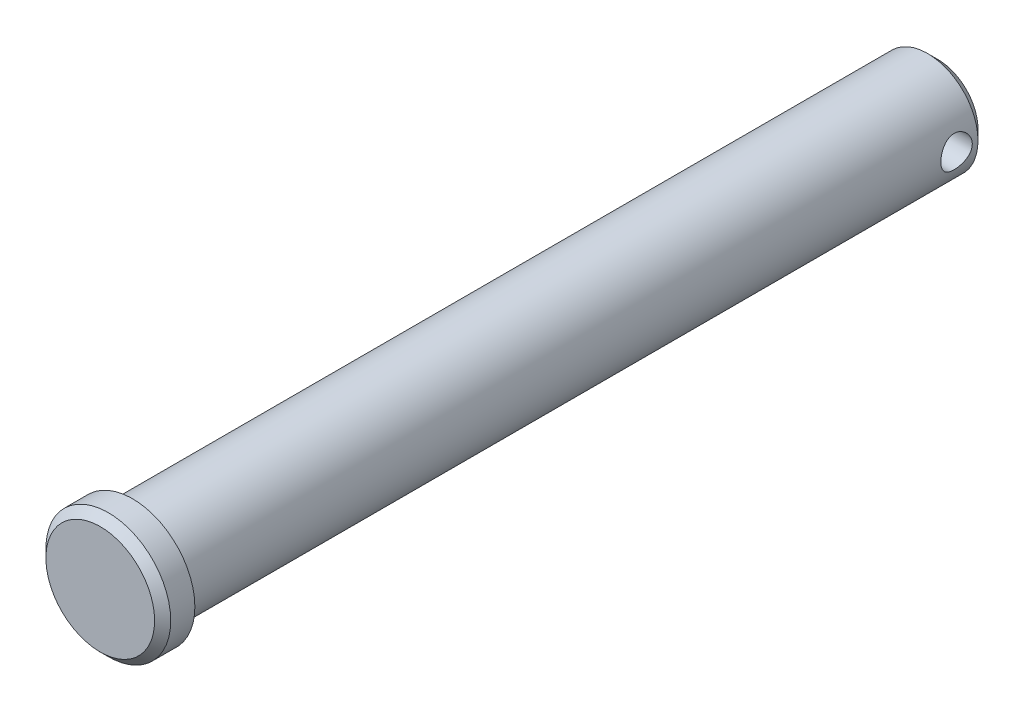
from build123d import *

# Parameters (mm, degrees)
CUT_EXTRUDE1_DEPTH      = 54.992777072
CUT_EXTRUDE1_DEPTH_BACK = 54.992777072
SKETCH3_R               = 1.9812


with BuildPart() as part:
    # Sketch2 → Revolve1 (revolve)
    with BuildSketch(Plane(origin=(0, 0, 0), x_dir=(0, 0, -1), z_dir=(1, 0, 0))):
        Polygon((51.562, 6.35), (-48.768, 6.35), (-48.768, 7.874), (-51.816, 7.874), (-52.832, 6.858), (-52.832, 0), (52.832, 0), (52.832, 5.08), align=None)
    revolve(axis=Axis((0, 0, 52.832), (0, 0, -1)))

    # Sketch3 → Cut-Extrude1 (cut, two sides: drawn at the far end of the back side and taken through both)
    with BuildSketch(Plane(origin=(0, 0, 0), x_dir=(0, 0, -1), z_dir=(1, 0, 0)).offset(-CUT_EXTRUDE1_DEPTH_BACK)):
        with Locations((48.860075, 0)):
            Circle(SKETCH3_R)
    extrude(amount=CUT_EXTRUDE1_DEPTH + CUT_EXTRUDE1_DEPTH_BACK, mode=Mode.SUBTRACT)


solid = part.part
